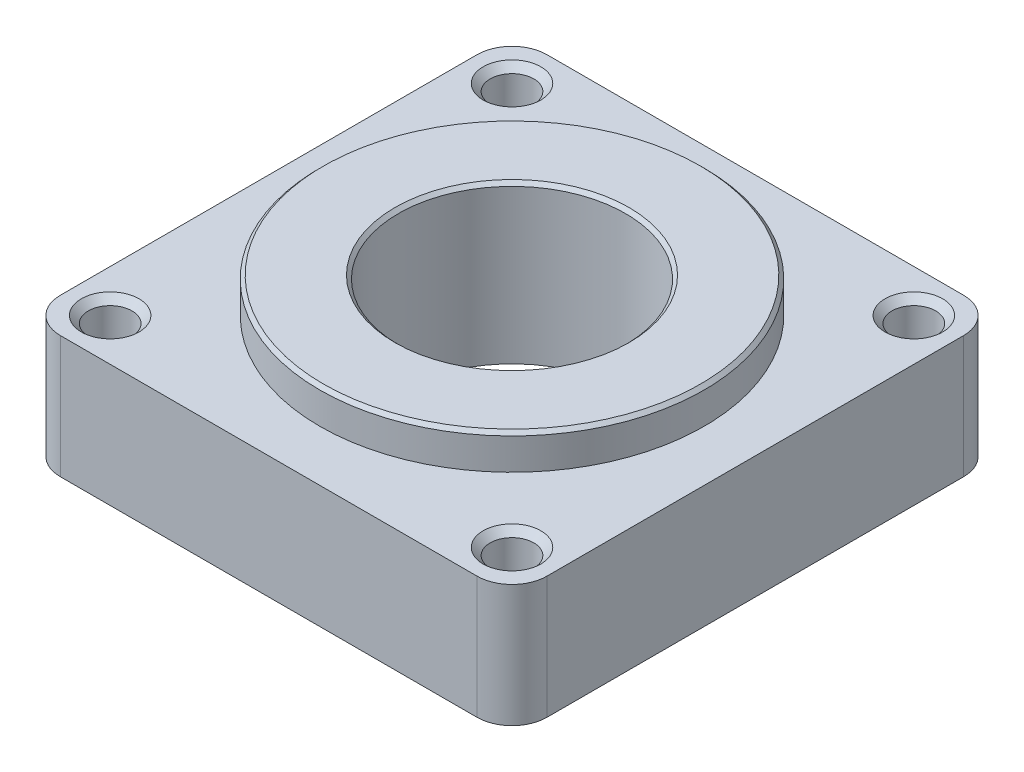
from build123d import *

# Parameters (mm, degrees)
SKETCH_1_W      = 27.85
SKETCH_1_H      = 27.85
SKETCH_1_R      = 1.25
SKETCH_1_R_2    = 6.5
EXTRUDE_1_DEPTH = 7
SKETCH_1_5_R    = 11
SKETCH_1_5_R_2  = 6.5
EXTRUDE_3_DEPTH = 9
CHAMFER_2_SIZE  = 0.4
CHAMFER_3_SIZE  = 0.2
FILLET_1_R      = 2


with BuildPart() as part:
    # Эскиз1 → Бобышка-Вытянуть1 (new body)
    with BuildSketch(Plane(origin=(0, 0, 0), x_dir=(1, 0, 0), z_dir=(0, 1, 0))):
        Rectangle(SKETCH_1_W, SKETCH_1_H)
        with Locations((-11.5, -11.5)):
            Circle(SKETCH_1_R, mode=Mode.SUBTRACT)
        with Locations((11.5, -11.5)):
            Circle(SKETCH_1_R, mode=Mode.SUBTRACT)
        with Locations((-11.5, 11.5)):
            Circle(SKETCH_1_R, mode=Mode.SUBTRACT)
        with Locations((11.5, 11.5)):
            Circle(SKETCH_1_R, mode=Mode.SUBTRACT)
        Circle(SKETCH_1_R_2, mode=Mode.SUBTRACT)
    extrude(amount=EXTRUDE_1_DEPTH)

    # Эскиз1<5> → Бобышка-Вытянуть3 (add)
    with BuildSketch(Plane(origin=(0, 0, 0), x_dir=(1, 0, 0), z_dir=(0, 1, 0))):
        Circle(SKETCH_1_5_R)
        Circle(SKETCH_1_5_R_2, mode=Mode.SUBTRACT)
    extrude(amount=EXTRUDE_3_DEPTH)

    # Фаска2
    chamfer_2_edges = [part.edges().sort_by_distance(p)[0] for p in [
        (10.25, 7, -11.5),
        (-12.75, 7, -11.5),
        (10.25, 7, 11.5),
        (-12.75, 7, 11.5),
    ]]
    chamfer(chamfer_2_edges, length=CHAMFER_2_SIZE)

    # Фаска3
    chamfer_3_edges = [part.edges().sort_by_distance(p)[0] for p in [
        (-11, 9, 0),
        (-6.5, 9, 0),
    ]]
    chamfer(chamfer_3_edges, length=CHAMFER_3_SIZE)

    # Скругление1
    fillet_1_edges = [part.edges().sort_by_distance(p)[0] for p in [
        (-13.925, 3.5, 13.925),
        (-13.925, 3.5, -13.925),
        (13.925, 3.5, -13.925),
        (13.925, 3.5, 13.925),
    ]]
    fillet(fillet_1_edges, radius=FILLET_1_R)


solid = part.part
